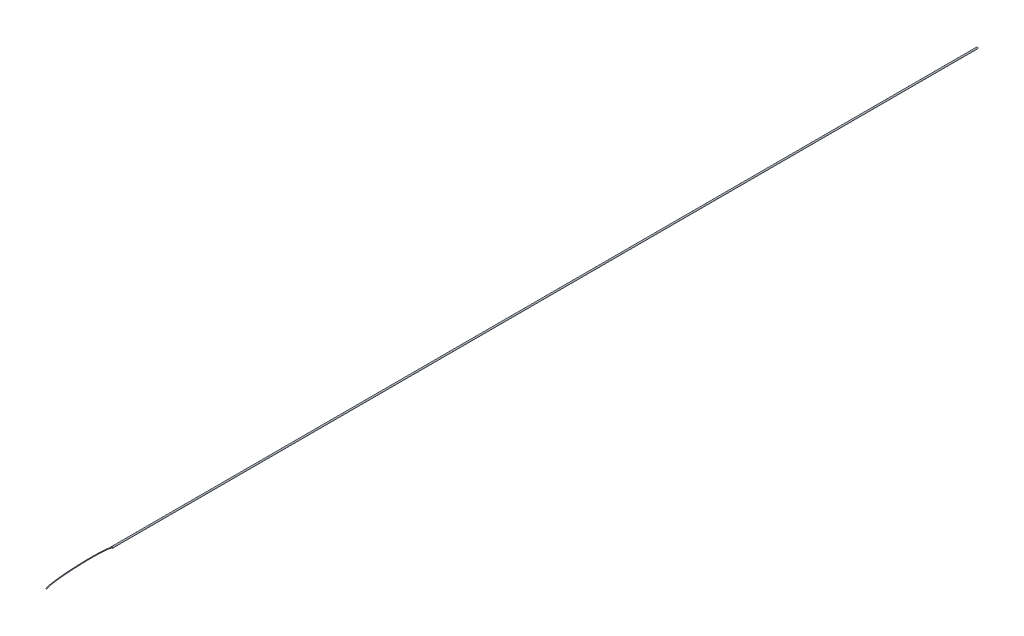
from build123d import *

# Parameters (mm, degrees)
SKETCH1_R = 1.143
SKETCH4_R = 0.5


with BuildPart() as part:
    # Sweep1: sweep along a path in Sketch3
    with BuildLine(Plane(origin=(0, 0, 0), x_dir=(1, 0, 0), z_dir=(0, 1, 0))) as sweep1_path:
        Line((0, 0), (0, -1389))
    # Sketch1 → Sweep1 (sweep)
    with BuildSketch(Plane.XY):
        Circle(SKETCH1_R)
    sweep(path=sweep1_path.line)

    # Sweep2: sweep along a curve in space
    with BuildLine() as sweep2_path:
        add(Edge.make_bspline(
            [(0, 0, 1389), (-1.568601671, 3.9259667, 1405.993410558), (17.529174685, 18.627064939, 1506.696772485), (18.843955102, 13.922308756, 1513)],
            knots=[0, 0, 0, 0, 1, 1, 1, 1], degree=3))
    # Sketch4 → Sweep2 (sweep)
    with BuildSketch(Plane.XY.offset(1389)):
        Circle(SKETCH4_R)
    sweep(path=sweep2_path.line, is_frenet=True)


solid = part.part
